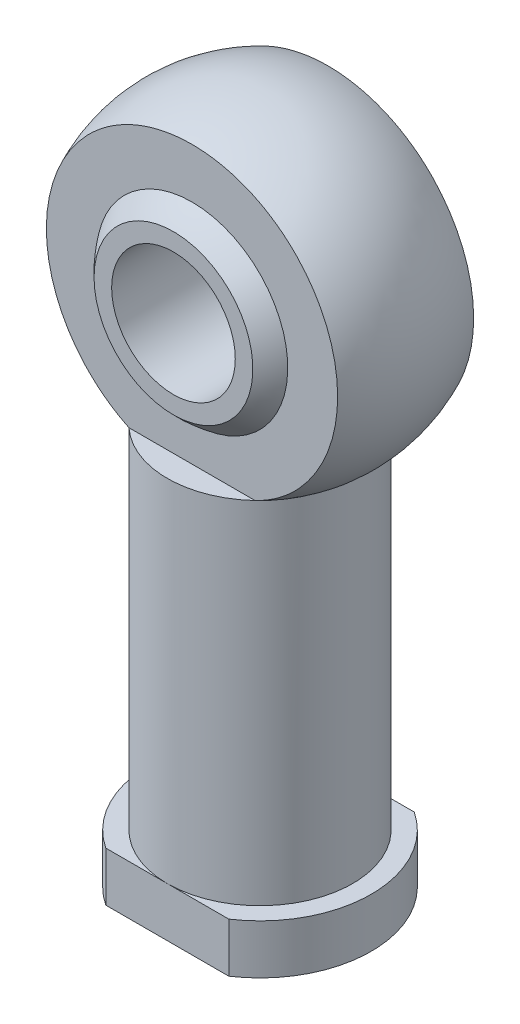
from build123d import *

# Parameters (mm, degrees)
CUT_EXTRUDE3_DEPTH      = 59.940648113
CUT_EXTRUDE3_DEPTH_BACK = 59.940648113
SKETCH3_W               = 17.579289035
SKETCH3_H               = 30.509322749
CUT_EXTRUDE4_DEPTH      = 59.268773799
CUT_EXTRUDE4_DEPTH_BACK = 59.268773799
SKETCH4_W               = 14.932737824
SKETCH4_H               = 19.875765969
CUT_EXTRUDE5_DEPTH      = 60.674114991
CUT_EXTRUDE5_DEPTH_BACK = 60.674114991
SKETCH5_R               = 5
CUT_EXTRUDE6_DEPTH      = 59.189346104
CUT_EXTRUDE6_DEPTH_BACK = 59.189346104
SKETCH6_W               = 15.994671042
SKETCH6_H               = 5.292782054


with BuildPart() as part:
    # Sketch1 → Revolve5 (revolve)
    with BuildSketch(Plane.XY):
        with BuildLine():
            Line((0, 52.5), (0, 53.5))
            ThreePointArc((0, 53.5), (-10.5, 43), (0, 32.5))
            Line((0, 32.5), (0, 33.5))
            ThreePointArc((0, 33.5), (-9.5, 43), (0, 52.5))
        make_face()
    revolve(axis=Axis((0, 0, 0), (0, 1, 0)))

    # Sketch1_7 → Revolve6 (revolve)
    with BuildSketch(Plane.XY):
        with BuildLine():
            Line((-7.5, 32.381619709), (-7.5, 4))
            Line((-7.5, 4), (-9, 4))
            Line((-9, 4), (-9, 0))
            Line((-9, 0), (0, 0))
            Line((0, 0), (0, 32.5))
            ThreePointArc((0, 32.5), (-10.5, 43), (0, 53.5))
            Line((0, 53.5), (0, 56))
            ThreePointArc((0, 56), (-12.39029749, 46.934530227), (-7.5, 32.381619709))
        make_face()
    revolve(axis=Axis((0, 0, 0), (0, 1, 0)))

    # Sketch3 → Cut-Extrude3 (cut, two sides: drawn at the far end of the back side and taken through both)
    with BuildSketch(Plane(origin=(0, 0, 0), x_dir=(0, 0, -1), z_dir=(1, 0, 0)).offset(-CUT_EXTRUDE3_DEPTH_BACK)):
        with Locations((-14.289644518, 47.636281084)):
            Rectangle(SKETCH3_W, SKETCH3_H)
        with Locations((14.289644518, 47.636281084)):
            Rectangle(SKETCH3_W, SKETCH3_H)
    extrude(amount=CUT_EXTRUDE3_DEPTH + CUT_EXTRUDE3_DEPTH_BACK, mode=Mode.SUBTRACT)

    # Sketch1_8 → Revolve7 (revolve)
    with BuildSketch(Plane.XY):
        with BuildLine():
            Line((0, 33.5), (0, 52.5))
            ThreePointArc((0, 52.5), (-9.5, 43), (0, 33.5))
        make_face()
    revolve(axis=Axis((0, 0, 0), (0, 1, 0)))

    # Sketch4 → Cut-Extrude4 (cut, two sides: drawn at the far end of the back side and taken through both)
    with BuildSketch(Plane(origin=(0, 0, 0), x_dir=(0, 0, -1), z_dir=(1, 0, 0)).offset(-CUT_EXTRUDE4_DEPTH_BACK)):
        with Locations((-14.466368912, 45.402031304)):
            Rectangle(SKETCH4_W, SKETCH4_H)
        with Locations((14.466368912, 45.402031304)):
            Rectangle(SKETCH4_W, SKETCH4_H)
    extrude(amount=CUT_EXTRUDE4_DEPTH + CUT_EXTRUDE4_DEPTH_BACK, mode=Mode.SUBTRACT)

    # Sketch5 → Cut-Extrude5 (cut, two sides: drawn at the far end of the back side and taken through both)
    with BuildSketch(Plane.XY.offset(7).offset(-CUT_EXTRUDE5_DEPTH_BACK)):
        with Locations((0, 43)):
            Circle(SKETCH5_R)
    extrude(amount=CUT_EXTRUDE5_DEPTH + CUT_EXTRUDE5_DEPTH_BACK, mode=Mode.SUBTRACT)

    # Sketch6 → Cut-Extrude6 (cut, two sides: drawn at the far end of the back side and taken through both)
    with BuildSketch(Plane(origin=(0, 0, 0), x_dir=(1, 0, 0), z_dir=(0, 1, 0)).offset(-CUT_EXTRUDE6_DEPTH_BACK)):
        with Locations((0.436218301, 10.146391027)):
            Rectangle(SKETCH6_W, SKETCH6_H)
        with Locations((0.436218301, -10.146391027)):
            Rectangle(SKETCH6_W, SKETCH6_H)
    extrude(amount=CUT_EXTRUDE6_DEPTH + CUT_EXTRUDE6_DEPTH_BACK, mode=Mode.SUBTRACT)


solid = part.part
